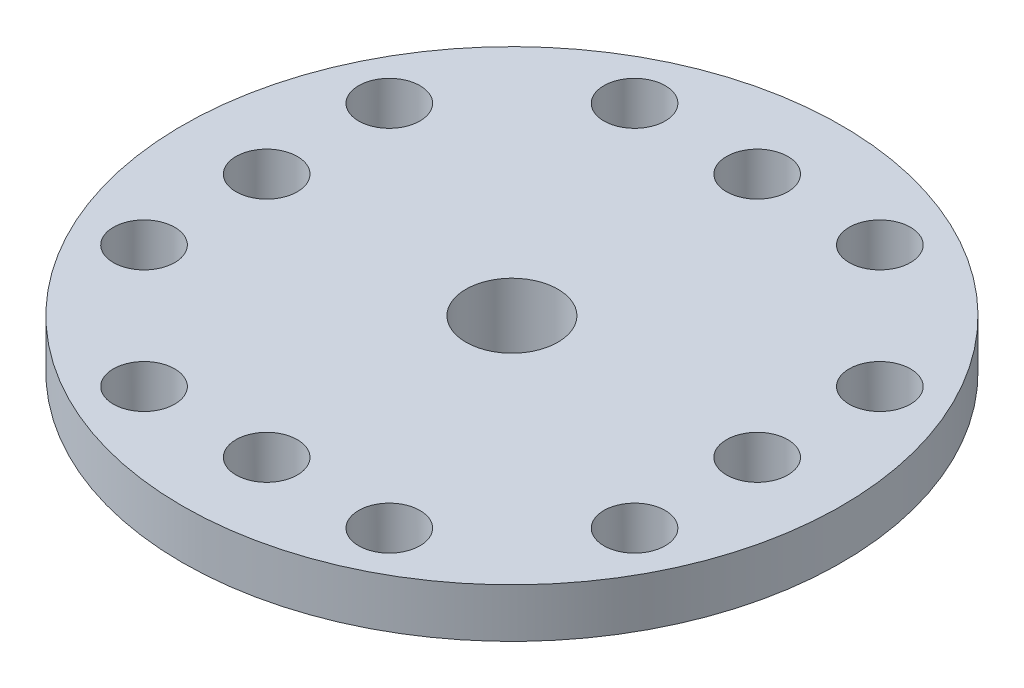
from build123d import *

# Parameters (mm, degrees)
SKETCH1_R           = 6
BOSS_EXTRUDE1_DEPTH = 7.5
SKETCH2_R           = 21.5
BOSS_EXTRUDE2_DEPTH = 3.2
SKETCH3_R           = 2
CUT_EXTRUDE1_DEPTH  = 11.7
SKETCH4_R           = 1.25
CUT_EXTRUDE2_DEPTH  = 11.7
CIRPATTERN1_COUNT   = 4
SKETCH5_R           = 3
CUT_EXTRUDE3_DEPTH  = 6.2
SKETCH6_R           = 3
CUT_EXTRUDE4_DEPTH  = 3.5


with BuildPart() as part:
    # Sketch1 → Boss-Extrude1 (new body)
    with BuildSketch(Plane(origin=(0, 0, 0), x_dir=(1, 0, 0), z_dir=(0, 1, 0))):
        Circle(SKETCH1_R)
    extrude(amount=BOSS_EXTRUDE1_DEPTH)

    # Sketch2 → Boss-Extrude2 (add)
    with BuildSketch(Plane(origin=(0, 7.5, 0), x_dir=(1, 0, 0), z_dir=(0, 1, 0))):
        Circle(SKETCH2_R)
    extrude(amount=BOSS_EXTRUDE2_DEPTH)

    # Sketch3 → Cut-Extrude1 (cut, through all)
    with BuildSketch(Plane(origin=(0, 10.7, 0), x_dir=(1, 0, 0), z_dir=(0, 1, 0))):
        with Locations((0, 16)):
            Circle(SKETCH3_R)
        with Locations((8, 16)):
            Circle(SKETCH3_R)
        with Locations((-8, 16)):
            Circle(SKETCH3_R)
    cut_extrude1 = extrude(amount=-CUT_EXTRUDE1_DEPTH, mode=Mode.SUBTRACT)

    # Sketch4 → Cut-Extrude2 (cut, through all)
    with BuildSketch(Plane(origin=(0, 10.7, 0), x_dir=(1, 0, 0), z_dir=(0, 1, 0))):
        Circle(SKETCH4_R)
    extrude(amount=-CUT_EXTRUDE2_DEPTH, mode=Mode.SUBTRACT)

    # CirPattern1: Cut-Extrude1 ×4 about axis
    cirpattern1_axis = Axis((0, 0, 0), (0, 1, 0))
    for i in range(1, CIRPATTERN1_COUNT):
        add(cut_extrude1.rotate(cirpattern1_axis, i * 360 / CIRPATTERN1_COUNT), mode=Mode.SUBTRACT)

    # Sketch5 → Cut-Extrude3 (cut)
    with BuildSketch(Plane(origin=(0, 10.7, 0), x_dir=(1, 0, 0), z_dir=(0, 1, 0))):
        Circle(SKETCH5_R)
    extrude(amount=-CUT_EXTRUDE3_DEPTH, mode=Mode.SUBTRACT)

    # Sketch6 → Cut-Extrude4 (cut)
    with BuildSketch(Plane.XZ):
        Circle(SKETCH6_R)
    extrude(amount=-CUT_EXTRUDE4_DEPTH, mode=Mode.SUBTRACT)


solid = part.part
